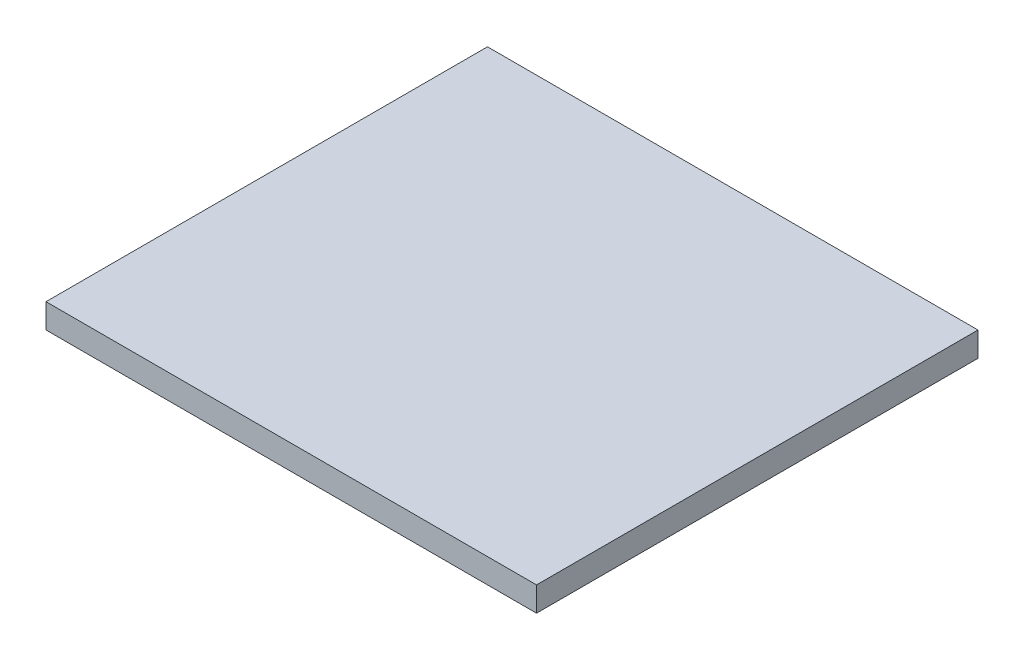
from build123d import *

# Parameters (mm, degrees)
SKETCH1_W           = 50.8
SKETCH1_H           = 45.72
BOSS_EXTRUDE2_DEPTH = 2.54


with BuildPart() as part:
    # Sketch1 → Boss-Extrude2 (new body)
    with BuildSketch(Plane(origin=(0, 0, 0), x_dir=(1, 0, 0), z_dir=(0, 1, 0))):
        with Locations((90.237277765, 149.963188414)):
            Rectangle(SKETCH1_W, SKETCH1_H)
    extrude(amount=BOSS_EXTRUDE2_DEPTH)


solid = part.part
